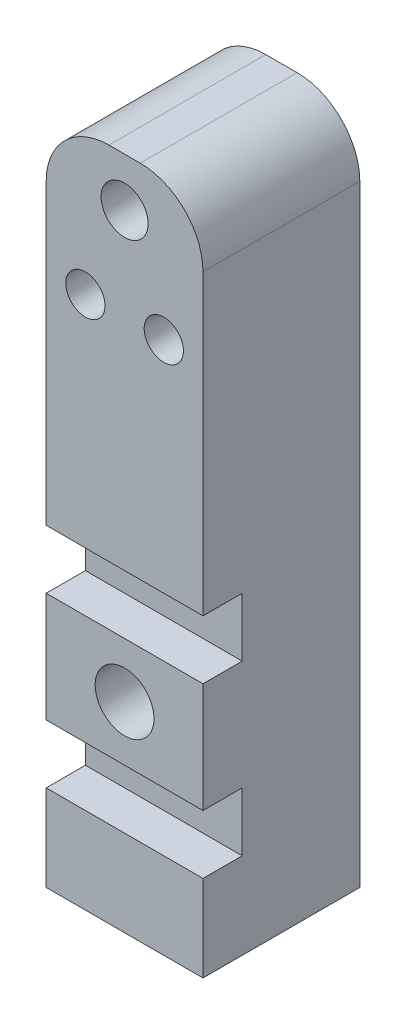
from build123d import *

# Parameters (mm, degrees)
SKETCH1_W             = 10
SKETCH1_H             = 23
SKETCH1_R             = 1.25
SKETCH1_R_2           = 1.5
BOSS_EXTRUDE1_DEPTH   = 10
SKETCH1_H_2           = 7
SKETCH1_R_3           = 1.875
BOSS_EXTRUDE1_2_DEPTH = 10
SKETCH1_H_3           = 5.5
BOSS_EXTRUDE1_3_DEPTH = 10
FILLET1_R             = 4
SKETCH2_R             = 1.536328734
BOSS_EXTRUDE3_DEPTH   = 3.5
SKETCH3_W             = 10
SKETCH3_H             = 3.920500842
BOSS_EXTRUDE4_DEPTH   = 7.5
SKETCH4_W             = 10
SKETCH4_H             = 3.773973311
BOSS_EXTRUDE5_DEPTH   = 7.5
SKETCH5_R             = 1
CUT_EXTRUDE1_DEPTH    = 7


with BuildPart() as part:
    # Sketch1 → Boss-Extrude1 (new body)
    with BuildSketch(Plane.XY):
        with Locations((0, 10)):
            Rectangle(SKETCH1_W, SKETCH1_H)
        with Locations((-2.5, 12.5)):
            Circle(SKETCH1_R, mode=Mode.SUBTRACT)
        with Locations((0, 18.4)):
            Circle(SKETCH1_R_2, mode=Mode.SUBTRACT)
        with Locations((2.5, 12.5)):
            Circle(SKETCH1_R, mode=Mode.SUBTRACT)
    extrude(amount=BOSS_EXTRUDE1_DEPTH)

    # Fillet1
    fillet1_edges = [part.edges().sort_by_distance(p)[0] for p in [
        (-5, 21.5, 5),
        (5, 21.5, 5),
    ]]
    fillet(fillet1_edges, radius=FILLET1_R)

    # Sketch2 → Boss-Extrude3 (add)
    with BuildSketch(Plane(origin=(0, 0, 0), x_dir=(-1, 0, 0), z_dir=(0, 0, -1))):
        with Locations((0, 18.4)):
            Circle(SKETCH2_R)
    extrude(amount=-BOSS_EXTRUDE3_DEPTH)



with BuildPart() as body_2:
    # Sketch1 → Boss-Extrude1 2 (new body)
    with BuildSketch(Plane.XY):
        with Locations((0, -8.75)):
            Rectangle(SKETCH1_W, SKETCH1_H_2)
        with Locations((0, -8.75)):
            Circle(SKETCH1_R_3, mode=Mode.SUBTRACT)
    extrude(amount=BOSS_EXTRUDE1_2_DEPTH)


with BuildPart() as body_3:
    # Sketch1 → Boss-Extrude1 3 (new body)
    with BuildSketch(Plane.XY):
        with Locations((0, -18.75)):
            Rectangle(SKETCH1_W, SKETCH1_H_3)
    extrude(amount=BOSS_EXTRUDE1_3_DEPTH)


with BuildPart() as part_1:
    add(part.part)

    add(body_2.part)  # Boss-Extrude4 merges body 2
    # Sketch3 → Boss-Extrude4 (add)
    with BuildSketch(Plane(origin=(0, 0, 0), x_dir=(-1, 0, 0), z_dir=(0, 0, -1))):
        with Locations((0, -3.289749579)):
            Rectangle(SKETCH3_W, SKETCH3_H)
    extrude(amount=-BOSS_EXTRUDE4_DEPTH)


    add(body_3.part)  # Boss-Extrude5 merges body 3
    # Sketch4 → Boss-Extrude5 (add)
    with BuildSketch(Plane(origin=(0, 0, 0), x_dir=(-1, 0, 0), z_dir=(0, 0, -1))):
        with Locations((0, -14.113013345)):
            Rectangle(SKETCH4_W, SKETCH4_H)
    extrude(amount=-BOSS_EXTRUDE5_DEPTH)

    # Sketch5 → Cut-Extrude1 (cut)
    with BuildSketch(Plane.XZ.offset(21.5)):
        with Locations((0, 5)):
            Circle(SKETCH5_R)
    extrude(amount=-CUT_EXTRUDE1_DEPTH, mode=Mode.SUBTRACT)


solid = part_1.part
